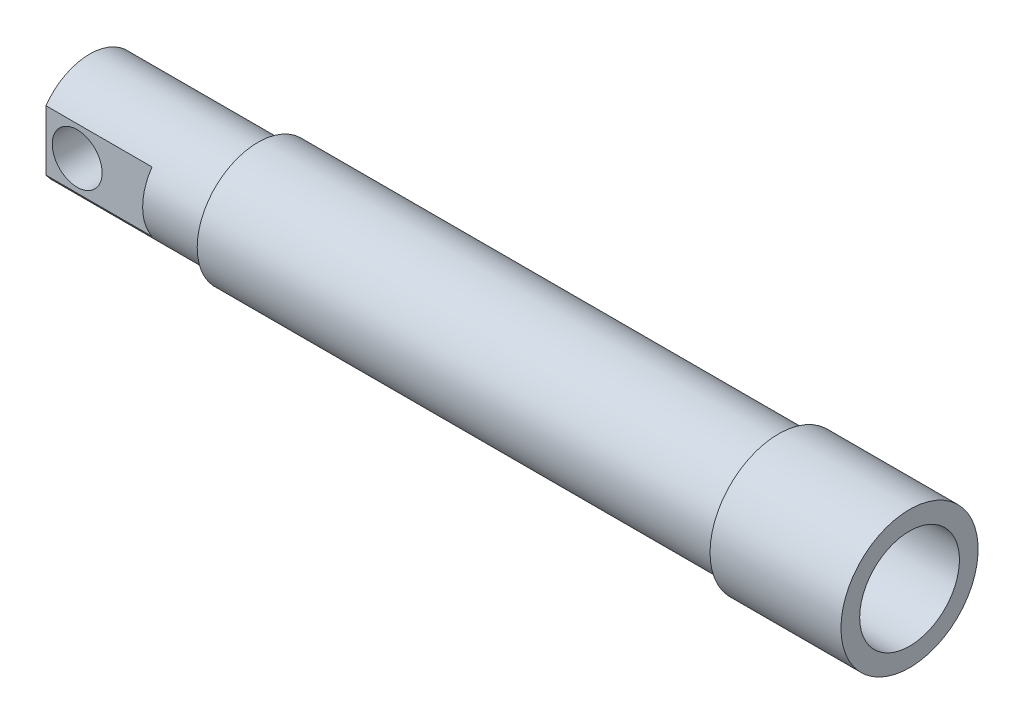
from build123d import *

# Parameters (mm, degrees)
SKETCH2_R           = 26.9875
BOSS_EXTRUDE1_DEPTH = 85.725
CUT_EXTRUDE1_DEPTH  = 53.975
SKETCH4_R           = 12.7
CUT_EXTRUDE2_DEPTH  = 58.15
SKETCH8_R           = 12.7
CUT_EXTRUDE3_DEPTH  = 26.9875


with BuildPart() as part:
    # Sketch1 → Revolve1 (revolve)
    with BuildSketch(Plane.XY):
        Polygon((165.89375, 34.925), (99.21875, 34.925), (99.21875, 30.95625), (-165.89375, 30.95625), (-165.89375, 25.4), (165.89375, 25.4), align=None)
    revolve(axis=Axis((-165.89375, 0, 0), (1, 0, 0)))

    # Sketch2 → Boss-Extrude1 (add)
    with BuildSketch(Plane.ZY.offset(165.89375)):
        Circle(SKETCH2_R)
    extrude(amount=BOSS_EXTRUDE1_DEPTH)

    # Sketch3 → Cut-Extrude1 (cut)
    with BuildSketch(Plane.ZY.offset(251.61875)):
        with BuildLine():
            Line((-22.225, 15.309295583), (-22.225, -15.309295583))
            ThreePointArc((-22.225, -15.309295583), (-26.9875, 0), (-22.225, 15.309295583))
        make_face()
        with BuildLine():
            Line((22.225, 15.309295583), (22.225, -15.309295583))
            ThreePointArc((22.225, -15.309295583), (26.9875, 0), (22.225, 15.309295583))
        make_face()
    extrude(amount=-CUT_EXTRUDE1_DEPTH, mode=Mode.SUBTRACT)

    # Sketch4 → Cut-Extrude2 (cut, through all)
    with BuildSketch(Plane.XY.offset(22.225)):
        with Locations((-235.74375, 0)):
            Circle(SKETCH4_R)
    extrude(amount=-CUT_EXTRUDE2_DEPTH, mode=Mode.SUBTRACT)

    # Sketch6 → 1/4 NPT Tapped Hole1 (revolve, cut)
    with BuildSketch(Plane(origin=(-181.76875, 0, -26.9875), x_dir=(0, 1, 0), z_dir=(1, 0, 0))):
        Polygon((0, 0), (0, 20.411147279), (5.5626, 17.0688), (5.5626, 10.0203), (6.557978799, 10.0203), (6.858, 0), align=None)
    revolve(axis=Axis((-181.76875, 0, -33.3375), (0, 0, 1)), mode=Mode.SUBTRACT)

    # Sketch8 → Cut-Extrude3 (cut)
    with BuildSketch(Plane(origin=(-165.89375, 0, 0), x_dir=(0, 0, -1), z_dir=(1, 0, 0))):
        Circle(SKETCH8_R)
    extrude(amount=-CUT_EXTRUDE3_DEPTH, mode=Mode.SUBTRACT)


solid = part.part
